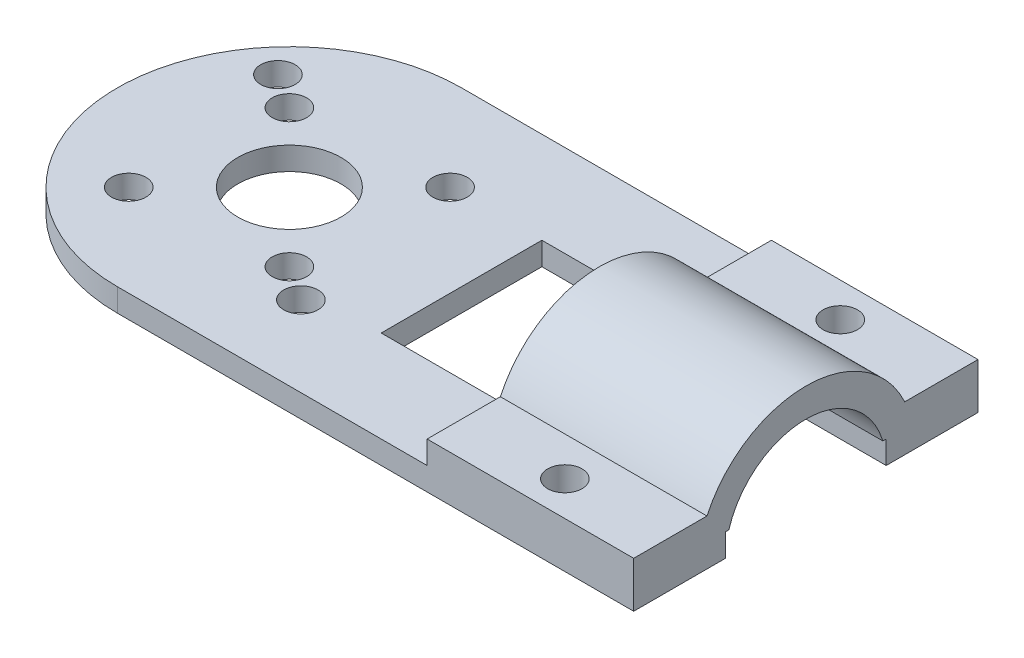
from build123d import *

# Parameters (mm, degrees)
ESBO_O1_R                = 4.5
ESBO_O1_R_2              = 1.5
RESSALTO_EXTRUS_O1_DEPTH = 2
RESSALTO_EXTRUS_O2_DEPTH = 18
ESBO_O3_R                = 7
CORTE_EXTRUS_O1_DEPTH    = 18
ESBO_O4_R                = 1.5
CORTE_EXTRUS_O2_DEPTH    = 17


with BuildPart() as part:
    # Esboço1 → Ressalto-extrusão1 (new body)
    with BuildSketch(Plane(origin=(0, 0, 0), x_dir=(1, 0, 0), z_dir=(0, 1, 0))):
        with BuildLine():
            Line((30, 15), (30, 7))
            Line((30, 7), (0, 7))
            Line((0, 7), (0, -7))
            Line((0, -7), (30, -7))
            Line((30, -7), (30, -15))
            Line((30, -15), (-15, -15))
            ThreePointArc((-15, -15), (-30, 0), (-15, 15))
            Line((-15, 15), (30, 15))
        make_face()
        with Locations((-15, 0)):
            Circle(ESBO_O1_R, mode=Mode.SUBTRACT)
        with Locations((-9, -6)):
            Circle(ESBO_O1_R_2, mode=Mode.SUBTRACT)
        with Locations((-6, -8)):
            Circle(ESBO_O1_R_2, mode=Mode.SUBTRACT)
        with Locations((-22, -7)):
            Circle(ESBO_O1_R_2, mode=Mode.SUBTRACT)
        with Locations((-21, 6)):
            Circle(ESBO_O1_R_2, mode=Mode.SUBTRACT)
        with Locations((-24, 8)):
            Circle(ESBO_O1_R_2, mode=Mode.SUBTRACT)
        with Locations((-8, 7)):
            Circle(ESBO_O1_R_2, mode=Mode.SUBTRACT)
    extrude(amount=RESSALTO_EXTRUS_O1_DEPTH)

    # Esboço2 → Ressalto-extrusão2 (add)
    with BuildSketch(Plane(origin=(30, 0, 0), x_dir=(0, 0, -1), z_dir=(1, 0, 0))):
        with BuildLine():
            Line((-15, 2), (-15, 4))
            Line((-15, 4), (-8.61684397, 4))
            ThreePointArc((-8.61684397, 4), (0, 9.5), (8.61684397, 4))
            Line((8.61684397, 4), (15, 4))
            Line((15, 4), (15, 2))
            Line((15, 2), (-15, 2))
        make_face()
    extrude(amount=-RESSALTO_EXTRUS_O2_DEPTH)

    # Esboço3 → Corte-extrusão1 (cut)
    with BuildSketch(Plane(origin=(30, 0, 0), x_dir=(0, 0, -1), z_dir=(1, 0, 0))):
        Circle(ESBO_O3_R)
    extrude(amount=-CORTE_EXTRUS_O1_DEPTH, mode=Mode.SUBTRACT)

    # Esboço4 → Corte-extrusão2 (cut)
    with BuildSketch(Plane(origin=(0, 4, 0), x_dir=(1, 0, 0), z_dir=(0, 1, 0))):
        with Locations((21, 12)):
            Circle(ESBO_O4_R)
        with Locations((21, -12)):
            Circle(ESBO_O4_R)
    extrude(amount=-CORTE_EXTRUS_O2_DEPTH, mode=Mode.SUBTRACT)


solid = part.part
